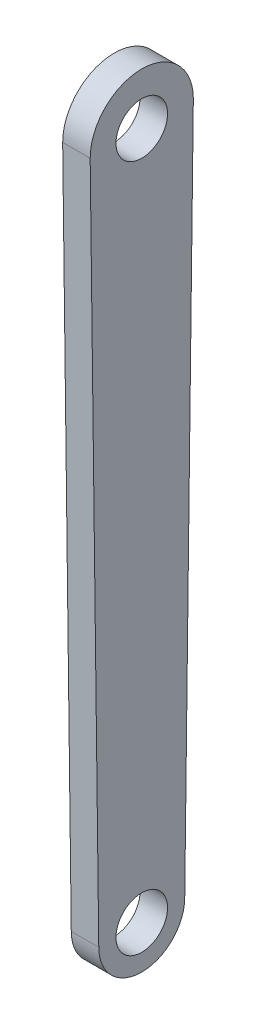
from build123d import *

# Parameters (mm, degrees)
EXTRUDE_1_DEPTH     = 8
SKETCH_2_R          = 7.5
CUT_EXTRUDE_1_DEPTH = 10


with BuildPart() as part:
    # 草图1 → 凸台-拉伸1 (new body)
    with BuildSketch(Plane(origin=(0, 0, 0), x_dir=(0, 0, -1), z_dir=(1, 0, 0))):
        with BuildLine():
            ThreePointArc((15, 0), (0, 15), (-15, 0))
            Line((-15, 0), (-12.5, -200))
            ThreePointArc((-12.5, -200), (0, -212.5), (12.5, -200))
            Line((12.5, -200), (15, 0))
        make_face()
    extrude(amount=EXTRUDE_1_DEPTH)

    # 草图2 → 切除-拉伸1 (cut)
    with BuildSketch(Plane(origin=(8, 0, 0), x_dir=(0, 0, -1), z_dir=(1, 0, 0))):
        Circle(SKETCH_2_R)
        with Locations((0, -200)):
            Circle(SKETCH_2_R)
    extrude(amount=-CUT_EXTRUDE_1_DEPTH, mode=Mode.SUBTRACT)


solid = part.part
